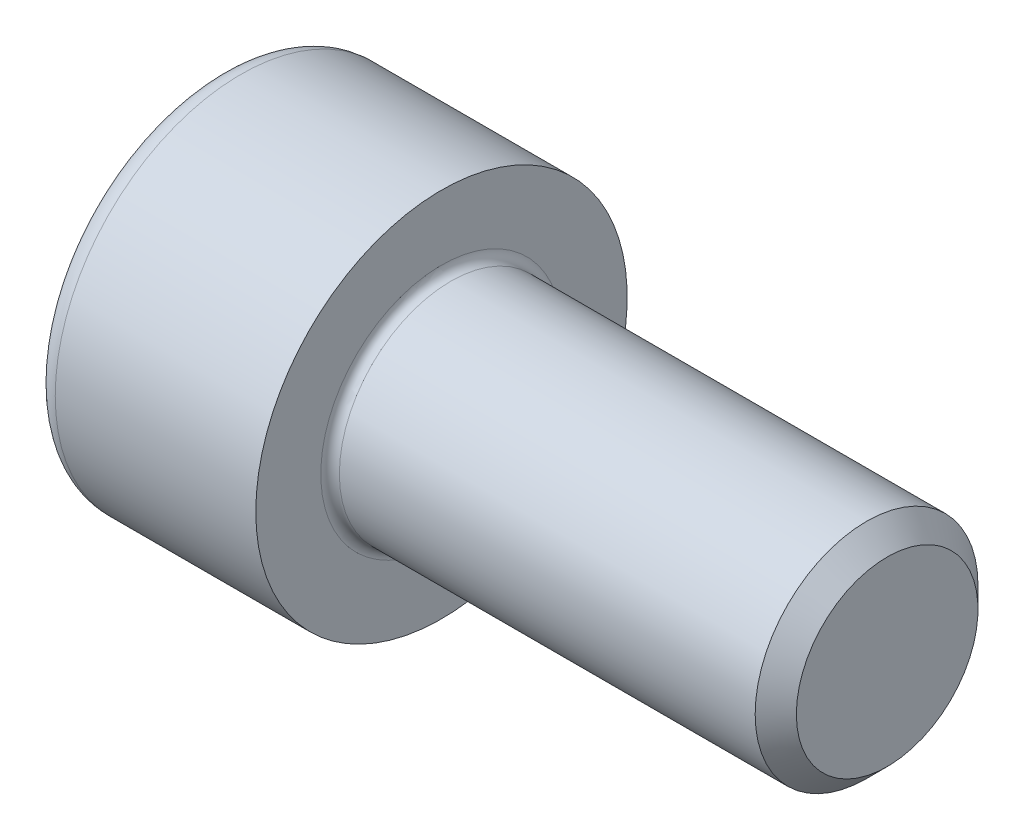
from build123d import *

# Parameters (mm, degrees)
FILLET1_R   = 0.25
FILLET2_R   = 0.6
HEX_2_DEPTH = 3


with BuildPart() as part:
    # BodySke → Base-Revolve (revolve)
    with BuildSketch(Plane.XY):
        Polygon((0, 0), (0, 5), (6, 5), (6, 3), (17.4455, 3), (18, 2.4455), (18, 0), align=None)
    revolve(axis=Axis((-31.75, 0, 0), (1, 0, 0)))

    # Fillet1
    fillet1_edges = [part.edges().sort_by_distance(p)[0] for p in [
        (6, -3, 0),
    ]]
    fillet(fillet1_edges, radius=FILLET1_R)

    # Fillet2
    fillet2_edges = [part.edges().sort_by_distance(p)[0] for p in [
        (0, -5, 0),
    ]]
    fillet(fillet2_edges, radius=FILLET2_R)

    # Sketch2 → Hex-PreBroach (revolve, cut)
    with BuildSketch(Plane.XY):
        Polygon((0, 2.51), (3, 2.51), (4.449149176, 0), (0, 0), align=None)
    revolve(axis=Axis((0, 0, 0), (1, 0, 0)), mode=Mode.SUBTRACT)

    # Sketch3 → Hex 2 (cut)
    with BuildSketch(Plane(origin=(0, 0, 0), x_dir=(0, 0.5, 0.866025404), z_dir=(-1, 0, 0))):
        Polygon((1.449149176, 2.51), (-1.449149176, 2.51), (-2.898298351, 0), (-1.449149176, -2.51), (1.449149176, -2.51), (2.898298351, 0), align=None)
    extrude(amount=-HEX_2_DEPTH, mode=Mode.SUBTRACT)


solid = part.part
